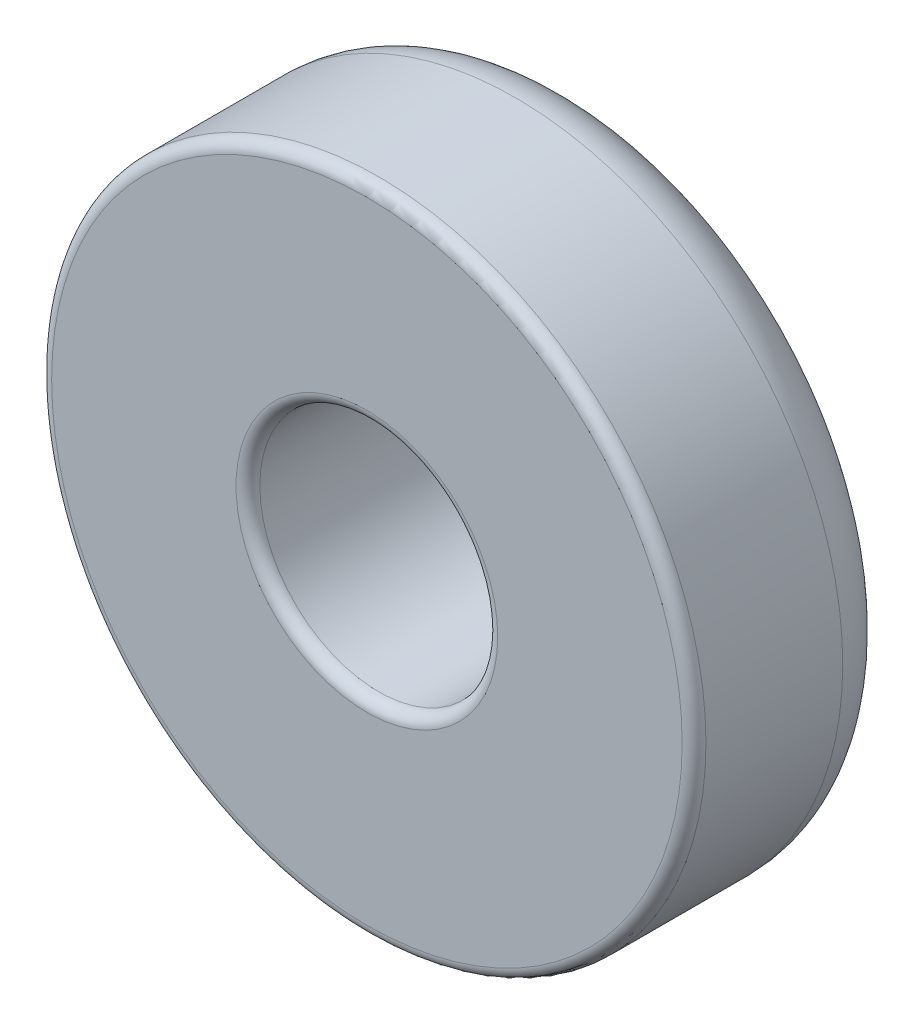
from build123d import *

# Parameters (mm, degrees)
SKETCH2_R           = 2.75
SKETCH2_R_2         = 1
EXTRUDE_THIN1_DEPTH = 1.75
FILLET1_R           = 0.5
FILLET2_R           = 0.1


with BuildPart() as part:
    # Sketch2 → Extrude-Thin1 (new body)
    with BuildSketch(Plane.XY):
        Circle(SKETCH2_R)
        Circle(SKETCH2_R_2, mode=Mode.SUBTRACT)
    extrude(amount=EXTRUDE_THIN1_DEPTH)

    # Fillet1
    fillet1_edges = [part.edges().sort_by_distance(p)[0] for p in [
        (-2.75, 0, 0),
    ]]
    fillet(fillet1_edges, radius=FILLET1_R)

    # Fillet2
    fillet2_edges = [part.edges().sort_by_distance(p)[0] for p in [
        (-1, 0, 0),
        (-2.75, 0, 1.75),
        (-1, 0, 1.75),
    ]]
    fillet(fillet2_edges, radius=FILLET2_R)


solid = part.part
